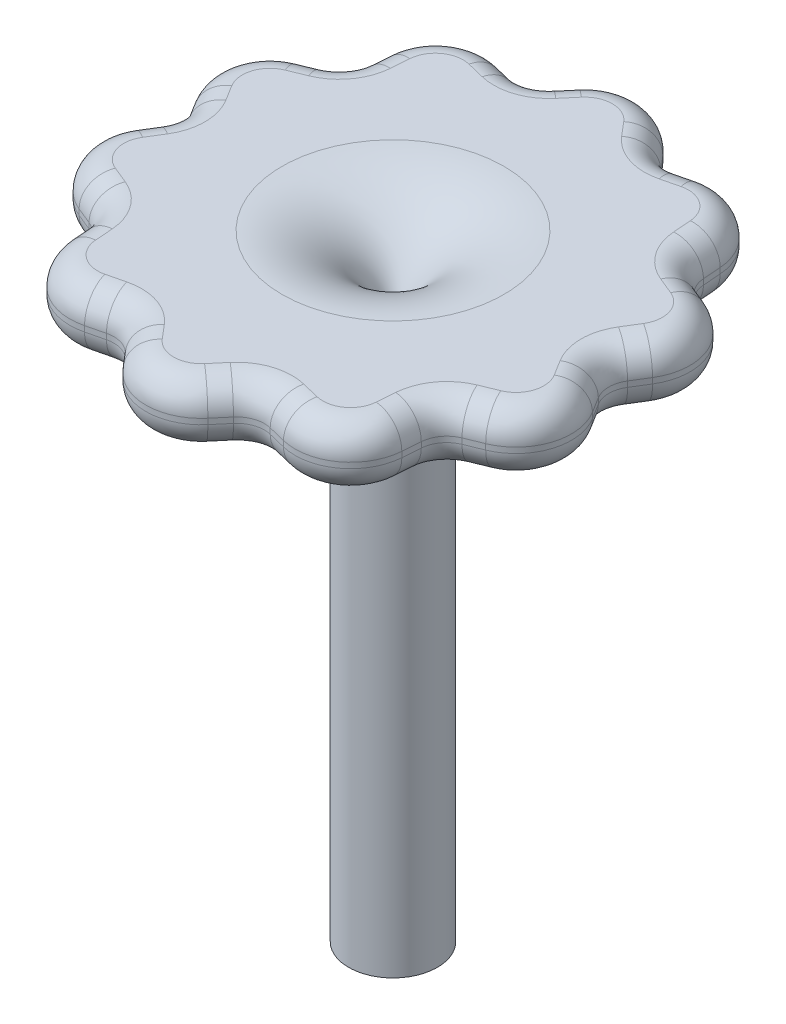
from build123d import *

# Parameters (mm, degrees)
SKETCH2_OUTSIDE_W = 137.956
SKETCH2_OUTSIDE_H = 137.956
EXTRUDE1_DEPTH    = 40
CONG_1_R          = 10
CONG_2_R          = 10
CONG_3_R          = 10
CONG_4_R          = 10
CONG_5_R          = 10
CONG_6_R          = 10
CONG_7_R          = 10
CONG_8_R          = 10
CONG_9_R          = 10
CONG_10_R         = 10
FILLET1_R         = 5


with BuildPart() as part:
    # Sketch1 → Revolve1 (revolve)
    with BuildSketch(Plane.XY):
        with BuildLine():
            Line((0, 0), (8, 0))
            Line((8, 0), (8, 80))
            ThreePointArc((8, 80), (13.857864376, 94.142135624), (28, 100))
            Line((28, 100), (45, 100))
            ThreePointArc((45, 100), (48.535533906, 101.464466094), (50, 105))
            Line((50, 105), (50, 106))
            ThreePointArc((50, 106), (48.535533906, 109.535533906), (45, 111))
            Line((45, 111), (20, 111))
            ThreePointArc((20, 111), (5.857864376, 105.142135624), (0, 91))
            Line((0, 91), (0, 0))
        make_face()
    revolve(axis=Axis((0, 0, 0), (0, 1, 0)))

    # Sketch2 outside → Extrude1 (cut)
    with BuildSketch(Plane(origin=(0, 111, 0), x_dir=(1, 0, 0), z_dir=(0, 1, 0))):
        Rectangle(SKETCH2_OUTSIDE_W, SKETCH2_OUTSIDE_H)
        Polygon((-29.389262615, -40.450849719), (-30.742645786, -22.335839587), (-47.552825815, -15.450849719), (-38, 0), (-47.552825815, 15.450849719), (-30.742645786, 22.335839587), (-29.389262615, 40.450849719), (-11.742645786, 36.140147619), (0, 50), (11.742645786, 36.140147619), (29.389262615, 40.450849719), (30.742645786, 22.335839587), (47.552825815, 15.450849719), (38, 0), (47.552825815, -15.450849719), (30.742645786, -22.335839587), (29.389262615, -40.450849719), (11.742645786, -36.140147619), (0, -50), (-11.742645786, -36.140147619), align=None, mode=Mode.SUBTRACT)
    extrude(amount=-EXTRUDE1_DEPTH, mode=Mode.SUBTRACT)

    # Congé1
    cong_1_edges = [part.edges().sort_by_distance(p)[0] for p in [
        (-47.552825815, 105.5, 15.450849719),
    ]]
    fillet(cong_1_edges, radius=CONG_1_R)

    # Congé2
    cong_2_edges = [part.edges().sort_by_distance(p)[0] for p in [
        (-29.389262615, 105.5, 40.450849719),
    ]]
    fillet(cong_2_edges, radius=CONG_2_R)

    # Congé3
    cong_3_edges = [part.edges().sort_by_distance(p)[0] for p in [
        (0, 105.5, 50),
    ]]
    fillet(cong_3_edges, radius=CONG_3_R)

    # Congé4
    cong_4_edges = [part.edges().sort_by_distance(p)[0] for p in [
        (29.389262615, 105.5, 40.450849719),
    ]]
    fillet(cong_4_edges, radius=CONG_4_R)

    # Congé5
    cong_5_edges = [part.edges().sort_by_distance(p)[0] for p in [
        (47.552825815, 105.5, 15.450849719),
    ]]
    fillet(cong_5_edges, radius=CONG_5_R)

    # Congé6
    cong_6_edges = [part.edges().sort_by_distance(p)[0] for p in [
        (47.552825815, 105.5, -15.450849719),
    ]]
    fillet(cong_6_edges, radius=CONG_6_R)

    # Congé7
    cong_7_edges = [part.edges().sort_by_distance(p)[0] for p in [
        (29.389262615, 105.5, -40.450849719),
    ]]
    fillet(cong_7_edges, radius=CONG_7_R)

    # Congé8
    cong_8_edges = [part.edges().sort_by_distance(p)[0] for p in [
        (0, 105.5, -50),
    ]]
    fillet(cong_8_edges, radius=CONG_8_R)

    # Congé9
    cong_9_edges = [part.edges().sort_by_distance(p)[0] for p in [
        (-29.389262615, 105.5, -40.450849719),
    ]]
    fillet(cong_9_edges, radius=CONG_9_R)

    # Congé10
    cong_10_edges = [part.edges().sort_by_distance(p)[0] for p in [
        (-47.552825815, 105.5, -15.450849719),
    ]]
    fillet(cong_10_edges, radius=CONG_10_R)

    # Fillet1
    fillet1_edges = [part.edges().sort_by_distance(p)[0] for p in [
        (-14.833021442, 111, -36.895062227),
        (-11.742645786, 105.5, -36.140147619),
        (9.686207035, 111, -38.567363601),
        (11.742645786, 105.5, -36.140147619),
        (30.505633647, 111, -25.508242935),
        (30.742645786, 105.5, -22.335839587),
        (39.672945054, 111, -2.705840462),
        (38, 105.5, 0),
        (33.686539884, 111, 21.1301011),
        (30.742645786, 105.5, 22.335839587),
        (14.833021442, 111, 36.895062227),
        (11.742645786, 105.5, 36.140147619),
        (-33.686539884, 111, 21.1301011),
        (-39.672945054, 100, 2.705840462),
        (-42.350852187, 111, 13.760626028),
        (-42.350852187, 100, 13.760626028),
        (-30.505633647, 100, 25.508242935),
        (-14.833021442, 111, 36.895062227),
        (-26.174266104, 100, 36.025786647),
        (-26.174266104, 111, 36.025786647),
        (-9.686207035, 100, 38.567363601),
        (9.686207035, 111, 38.567363601),
        (0, 100, 44.530321239),
        (0, 111, 44.530321239),
        (14.833021442, 100, 36.895062227),
        (30.505633647, 111, 25.508242935),
        (26.174266104, 100, 36.025786647),
        (26.174266104, 111, 36.025786647),
        (33.686539884, 100, 21.1301011),
        (39.672945054, 111, 2.705840462),
        (42.350852187, 100, 13.760626028),
        (42.350852187, 111, 13.760626028),
        (39.672945054, 100, -2.705840462),
        (33.686539884, 111, -21.1301011),
        (42.350852187, 100, -13.760626028),
        (42.350852187, 111, -13.760626028),
        (9.686207035, 100, 38.567363601),
        (30.505633647, 100, -25.508242935),
        (14.833021442, 111, -36.895062227),
        (26.174266104, 100, -36.025786647),
        (26.174266104, 111, -36.025786647),
        (30.505633647, 100, 25.508242935),
        (9.686207035, 100, -38.567363601),
        (-9.686207035, 111, -38.567363601),
        (0, 100, -44.530321239),
        (0, 111, -44.530321239),
        (39.672945054, 100, 2.705840462),
        (-14.833021442, 100, -36.895062227),
        (-30.505633647, 111, -25.508242935),
        (-26.174266104, 100, -36.025786647),
        (-26.174266104, 111, -36.025786647),
        (33.686539884, 100, -21.1301011),
        (-33.686539884, 100, -21.1301011),
        (-39.672945054, 111, -2.705840462),
        (-42.350852187, 100, -13.760626028),
        (14.833021442, 100, -36.895062227),
        (-42.350852187, 111, -13.760626028),
        (-9.686207035, 100, -38.567363601),
        (-30.505633647, 100, -25.508242935),
        (-39.672945054, 100, -2.705840462),
        (-33.686539884, 100, 21.1301011),
        (-14.833021442, 100, 36.895062227),
        (-9.686207035, 111, 38.567363601),
        (-11.742645786, 105.5, 36.140147619),
        (-30.505633647, 111, 25.508242935),
        (-30.742645786, 105.5, 22.335839587),
        (-39.672945054, 111, 2.705840462),
        (-38, 105.5, 0),
        (-33.686539884, 111, -21.1301011),
        (-30.742645786, 105.5, -22.335839587),
    ]]
    fillet(fillet1_edges, radius=FILLET1_R)


solid = part.part
